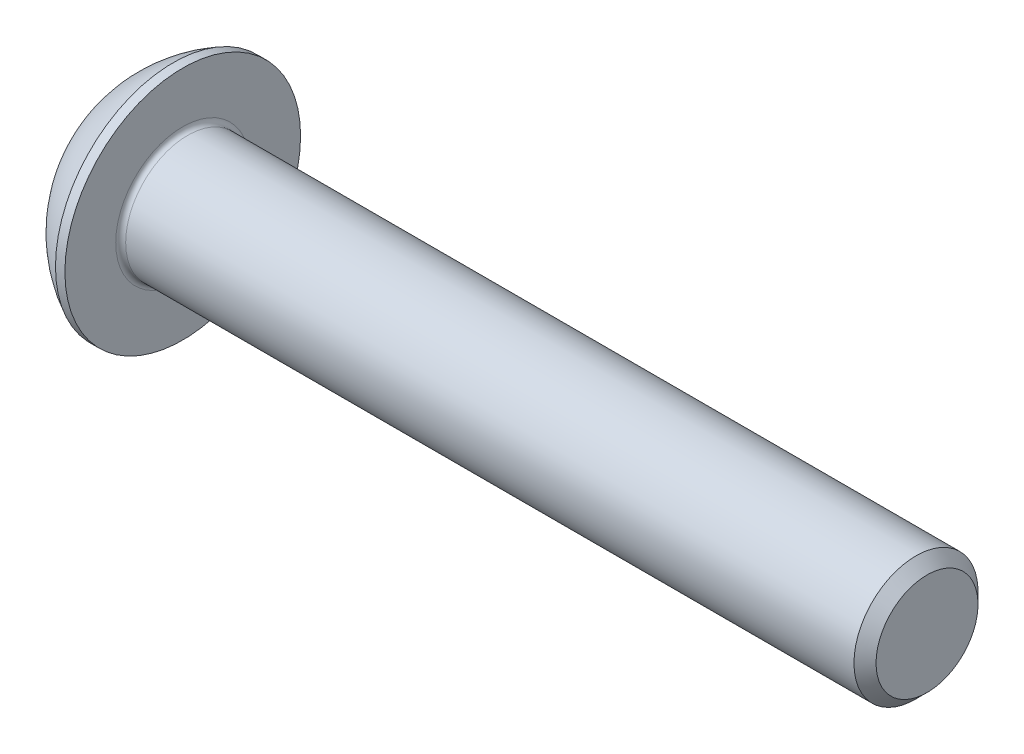
from build123d import *

# Parameters (mm, degrees)
FILLET1_R   = 0.2
HEX_2_DEPTH = 1.56


with BuildPart() as part:
    # BodySke → BaseBody (revolve)
    with BuildSketch(Plane.XY):
        with BuildLine():
            Line((32.75, 0), (32.75, 2.055))
            Line((32.75, 2.055), (32.305, 2.5))
            Line((32.305, 2.5), (2.75, 2.5))
            Line((2.75, 2.5), (2.75, 4.75))
            Line((2.75, 4.75), (2.37, 4.75))
            ThreePointArc((2.37, 4.75), (0.992680215, 3.754414901), (0, 2.375))
            Line((0, 2.375), (0, 0))
            Line((0, 0), (32.75, 0))
        make_face()
    revolve(axis=Axis((0, 0, 0), (1, 0, 0)))

    # Fillet1
    fillet1_edges = [part.edges().sort_by_distance(p)[0] for p in [
        (2.75, -2.5, 0),
    ]]
    fillet(fillet1_edges, radius=FILLET1_R)

    # Sketch2 → PreBroach (revolve, cut)
    with BuildSketch(Plane.XY):
        Polygon((0, 1.5), (1.56, 1.5), (2.426025404, 0), (0, 0), align=None)
    revolve(axis=Axis((0, 0, 0), (1, 0, 0)), mode=Mode.SUBTRACT)

    # Sketch3 → Hex 2 (cut)
    with BuildSketch(Plane(origin=(0, 0, 0), x_dir=(0, 0, -1), z_dir=(1, 0, 0))):
        Polygon((-1.5, -0.866025404), (-1.5, 0.866025404), (0, 1.732050808), (1.5, 0.866025404), (1.5, -0.866025404), (0, -1.732050808), align=None)
    extrude(amount=HEX_2_DEPTH, mode=Mode.SUBTRACT)


solid = part.part
